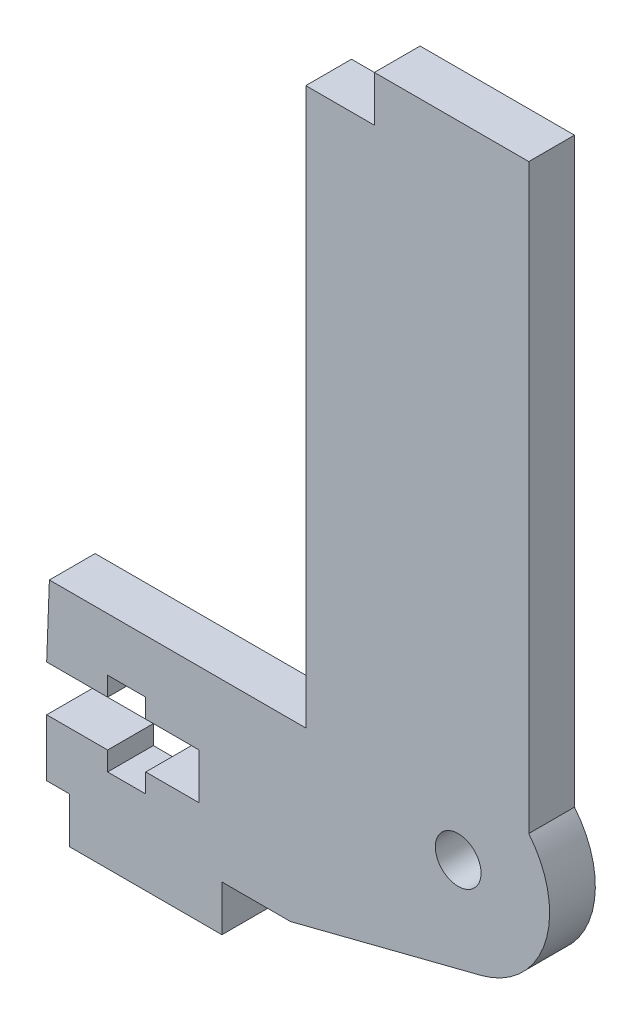
from build123d import *

# Parameters (mm, degrees)
MODEL_R             = 1.500000002
BOSS_EXTRUDE1_DEPTH = 3


with BuildPart() as part:
    # Model → Boss-Extrude1 (new body)
    with BuildSketch(Plane.XY):
        with BuildLine():
            Line((67.745687083, 17.48726701), (67.745687083, 21.23726701))
            Line((67.745687083, 21.23726701), (71.745687083, 21.23726701))
            Line((71.745687083, 21.23726701), (71.745687083, 19.98726701))
            Line((71.745687083, 19.98726701), (74.245687083, 19.98726701))
            Line((74.245687083, 19.98726701), (74.245687083, 21.23726701))
            Line((74.245687083, 21.23726701), (77.745687083, 21.23726701))
            Line((77.745687083, 21.23726701), (77.745687083, 24.23726701))
            Line((77.745687083, 24.23726701), (74.245687083, 24.23726701))
            Line((74.245687083, 24.23726701), (74.245687083, 25.48726701))
            Line((74.245687083, 25.48726701), (71.745687083, 25.48726701))
            Line((71.745687083, 25.48726701), (71.745687083, 24.23726701))
            Line((71.745687083, 24.23726701), (67.745687083, 24.23726701))
            Line((67.745687083, 24.23726701), (67.924311205, 28.98726701))
            Line((67.924311205, 28.98726701), (68.995687083, 28.98726701))
            Line((68.995687083, 28.98726701), (84.745617476, 28.98726701))
            Line((84.745617476, 28.98726701), (84.745617476, 65.48726701))
            Line((84.745617476, 65.48726701), (89.245617476, 65.48726701))
            Line((89.245617476, 65.48726701), (89.245617476, 68.48726701))
            Line((89.245617476, 68.48726701), (99.376117267, 68.48726701))
            Line((99.376117267, 68.48726701), (99.376117267, 65.487488154))
            Line((99.376117267, 65.487488154), (99.376117267, 30.302957894))
            ThreePointArc((99.376117267, 30.302957894), (100.4489582, 24.623653509), (96.229587083, 20.67366701))
            Line((96.229587083, 20.67366701), (83.745687083, 17.48726701))
            Line((83.745687083, 17.48726701), (79.245687083, 17.48726701))
            Line((79.245687083, 17.48726701), (79.245687083, 14.48726701))
            Line((79.245687083, 14.48726701), (69.245690135, 14.48726701))
            Line((69.245690135, 14.48726701), (69.245687083, 17.48726701))
            Line((69.245687083, 17.48726701), (67.745687083, 17.48726701))
        make_face()
        with Locations((94.745687081, 26.487267012)):
            Circle(MODEL_R, mode=Mode.SUBTRACT)
    extrude(amount=BOSS_EXTRUDE1_DEPTH)


solid = part.part
